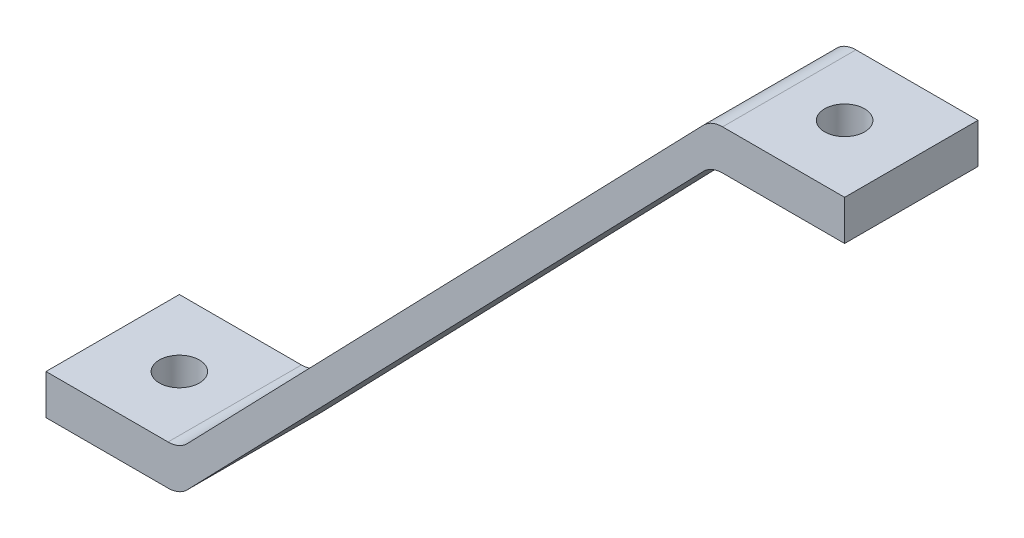
from build123d import *

# Parameters (mm, degrees)
SKETCH1_W               = 12.7
SKETCH1_H               = 12.7
BOSS_EXTRUDE1_DEPTH     = 3.81
BOSS_EXTRUDE2_DEPTH     = 12.7
FILLET1_R               = 2.54
SKETCH6_R               = 1.905
CUT_EXTRUDE1_DEPTH      = 53.3875
CUT_EXTRUDE1_DEPTH_BACK = 4.81


with BuildPart() as part:
    # Sketch1 → Boss-Extrude1 (new body)
    with BuildSketch(Plane(origin=(0, 0, 0), x_dir=(1, 0, 0), z_dir=(0, 1, 0))):
        with Locations((6.35, 6.35)):
            Rectangle(SKETCH1_W, SKETCH1_H)
    extrude(amount=BOSS_EXTRUDE1_DEPTH)

    # Sketch2 → Boss-Extrude2 (add)
    with BuildSketch(Plane.XY):
        Polygon((12.7, 0), (63.348255925, 52.3875), (76.048255925, 52.3875), (76.048255925, 56.1975), (63.348255925, 56.1975), (12.7, 3.81), align=None)
    extrude(amount=-BOSS_EXTRUDE2_DEPTH)

    # Fillet1
    fillet1_edges = [part.edges().sort_by_distance(p)[0] for p in [
        (12.7, 3.81, -6.35),
        (63.348255925, 56.1975, -6.35),
        (63.348255925, 52.3875, -6.35),
        (12.7, 0, -6.35),
    ]]
    fillet(fillet1_edges, radius=FILLET1_R)

    # Sketch6 → Cut-Extrude1 (cut, two sides)
    with BuildSketch(Plane(origin=(0, 3.81, 0), x_dir=(1, 0, 0), z_dir=(0, 1, 0))) as cut_extrude1_sk:
        with Locations((6.35, 6.35)):
            Circle(SKETCH6_R)
        with Locations((69.698255925, 6.35)):
            Circle(SKETCH6_R)
    extrude(amount=CUT_EXTRUDE1_DEPTH, mode=Mode.SUBTRACT)
    extrude(cut_extrude1_sk.sketch, amount=-CUT_EXTRUDE1_DEPTH_BACK, mode=Mode.SUBTRACT)


solid = part.part
